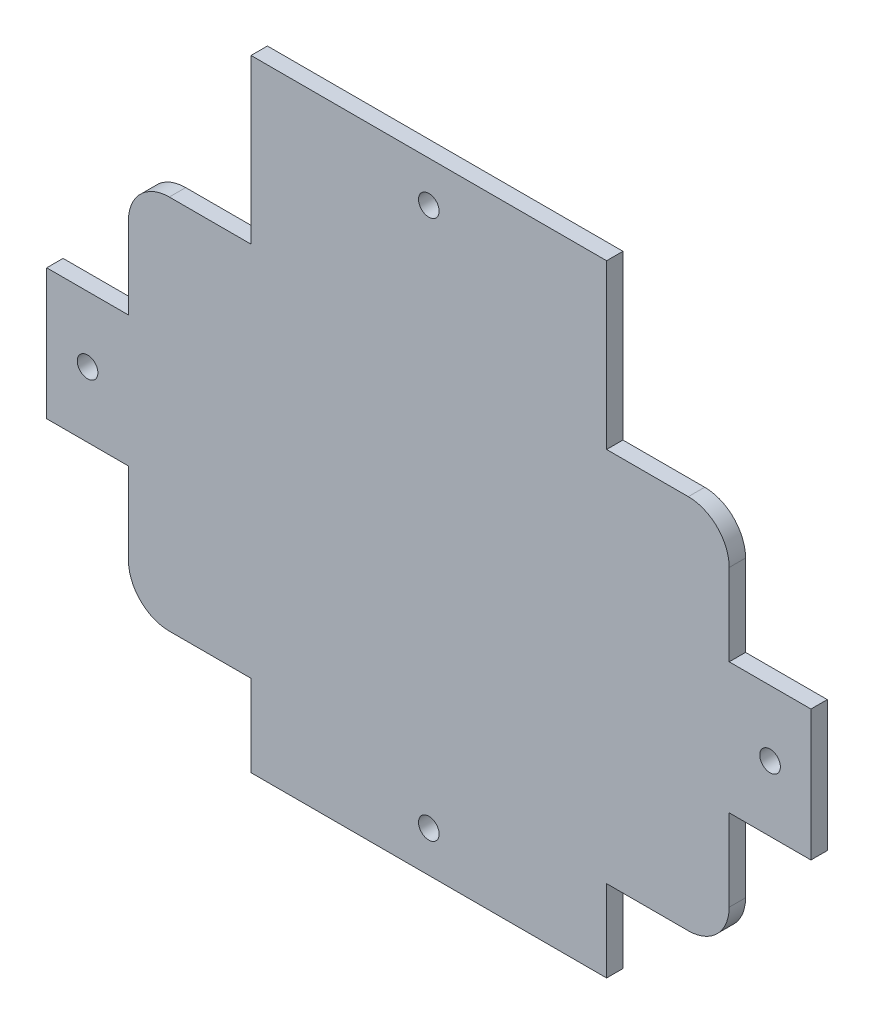
from build123d import *

# Parameters (mm, degrees)
SKETCH1_R           = 2.525
BOSS_EXTRUDE1_DEPTH = 4


with BuildPart() as part:
    # Sketch1 → Boss-Extrude1 (new body)
    with BuildSketch(Plane.XY):
        with BuildLine():
            Line((-43.5, 86), (-43.5, 46))
            Line((-43.5, 46), (-63.5, 46))
            ThreePointArc((-63.5, 46), (-70.571067812, 43.071067812), (-73.5, 36))
            Line((-73.5, 36), (-73.5, 16))
            Line((-73.5, 16), (-93.5, 16))
            Line((-93.5, 16), (-93.5, -16))
            Line((-93.5, -16), (-73.5, -16))
            Line((-73.5, -16), (-73.5, -36))
            ThreePointArc((-73.5, -36), (-70.571067812, -43.071067812), (-63.5, -46))
            Line((-63.5, -46), (-43.5, -46))
            Line((-43.5, -46), (-43.5, -66))
            Line((-43.5, -66), (43.5, -66))
            Line((43.5, -66), (43.5, -46))
            Line((43.5, -46), (63.5, -46))
            ThreePointArc((63.5, -46), (70.571067812, -43.071067812), (73.5, -36))
            Line((73.5, -36), (73.5, -16))
            Line((73.5, -16), (93.5, -16))
            Line((93.5, -16), (93.5, 16))
            Line((93.5, 16), (73.5, 16))
            Line((73.5, 16), (73.5, 36))
            ThreePointArc((73.5, 36), (70.571067812, 43.071067812), (63.5, 46))
            Line((63.5, 46), (43.5, 46))
            Line((43.5, 46), (43.5, 86))
            Line((43.5, 86), (-43.5, 86))
        make_face()
        with Locations((0, 76)):
            Circle(SKETCH1_R, mode=Mode.SUBTRACT)
        with Locations((-83.5, 0)):
            Circle(SKETCH1_R, mode=Mode.SUBTRACT)
        with Locations((83.5, 0)):
            Circle(SKETCH1_R, mode=Mode.SUBTRACT)
        with Locations((0, -56)):
            Circle(SKETCH1_R, mode=Mode.SUBTRACT)
    extrude(amount=BOSS_EXTRUDE1_DEPTH)


solid = part.part
